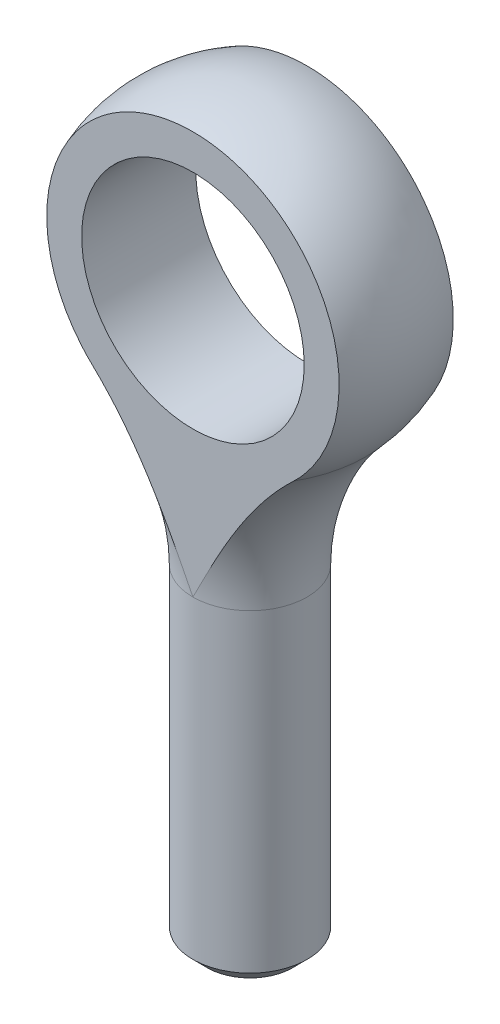
from build123d import *

# Parameters (mm, degrees)
SKETCH1_W               = 6.35
SKETCH1_H               = 36.5125
CHAMFER2_SIZE           = 1.5875
SKETCH5_W               = 11.1125
SKETCH5_H               = 46.0375
CUT_EXTRUDE1_DEPTH      = 18.4625
CUT_EXTRUDE1_DEPTH_BACK = 18.4625
SKETCH6_R               = 12.3825
CUT_EXTRUDE2_DEPTH      = 7.3500001
CUT_EXTRUDE2_DEPTH_BACK = 7.3500001
SCALE1_SCALE            = 0.75
SCALE2_SCALE            = 0.666666667


with BuildPart() as part:
    # Sketch1 → Revolve1 (revolve)
    with BuildSketch(Plane.XY):
        with Locations((3.175, -18.25625)):
            Rectangle(SKETCH1_W, SKETCH1_H)
    revolve(axis=Axis((0, 46.0375, 0), (0, -1, 0)))

    # Chamfer2
    chamfer2_edges = [part.edges().sort_by_distance(p)[0] for p in [
        (-6.35, -36.5125, 0),
    ]]
    chamfer(chamfer2_edges, length=CHAMFER2_SIZE)

    # Sketch4 → Revolve2 (revolve)
    with BuildSketch(Plane.XY):
        with BuildLine():
            Line((6.35, 0), (0, 0))
            Line((0, 0), (0, 46.0375))
            ThreePointArc((0, 46.0375), (15.983688754, 35.607823052), (12.874497319, 16.77727882))
            ThreePointArc((12.874497319, 16.77727882), (8.03853042, 9.000640948), (6.35, 0))
        make_face()
    revolve(axis=Axis((0, 46.0375, 0), (0, 1, 0)))

    # Sketch5 → Cut-Extrude1 (cut, two sides)
    with BuildSketch(Plane(origin=(0, 0, 0), x_dir=(0, 0, -1), z_dir=(1, 0, 0))) as cut_extrude1_sk:
        with Locations((11.90625, 23.01875)):
            Rectangle(SKETCH5_W, SKETCH5_H)
        with Locations((-11.90625, 23.01875)):
            Rectangle(SKETCH5_W, SKETCH5_H)
    extrude(amount=CUT_EXTRUDE1_DEPTH, mode=Mode.SUBTRACT)
    extrude(cut_extrude1_sk.sketch, amount=-CUT_EXTRUDE1_DEPTH_BACK, mode=Mode.SUBTRACT)

    # Sketch6 → Cut-Extrude2 (cut, two sides)
    with BuildSketch(Plane.XY) as cut_extrude2_sk:
        with Locations((0, 28.575)):
            Circle(SKETCH6_R)
    extrude(amount=CUT_EXTRUDE2_DEPTH, mode=Mode.SUBTRACT)
    extrude(cut_extrude2_sk.sketch, amount=-CUT_EXTRUDE2_DEPTH_BACK, mode=Mode.SUBTRACT)


with BuildPart() as part_1:
    # Scale1: scaled about (-0.000122935, 7.334416679, -0.001044289)
    add(part.part.scale(SCALE1_SCALE).moved(Location((-3.0734e-05, 1.83360417, -0.000261072))))


with BuildPart() as part_2:
    # Scale2: scaled about (-0.000122935, 7.334416679, -0.001044289)
    add(part_1.part.scale(SCALE2_SCALE).moved(Location((-4.0978e-05, 2.44480556, -0.000348096))))


solid = part_2.part
